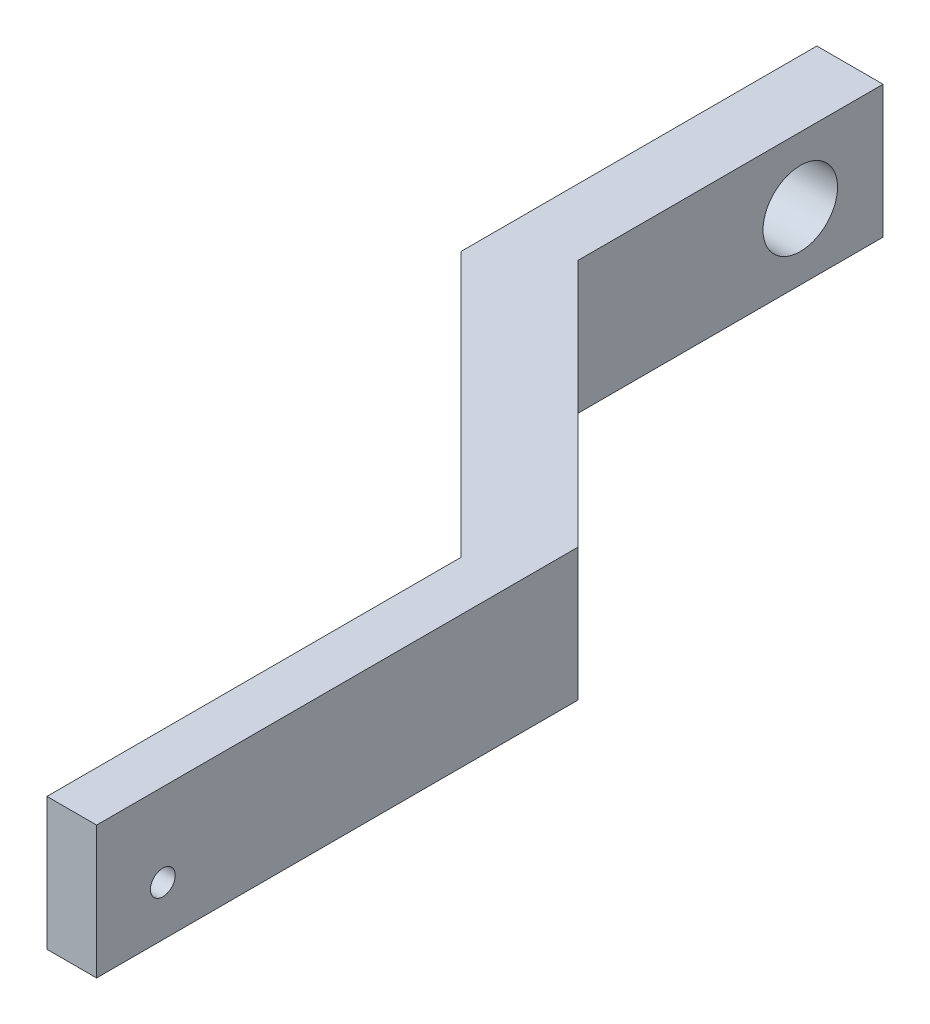
from build123d import *

# Parameters (mm, degrees)
BOSS_EXTRUDE1_DEPTH     = 8
SKETCH2_R               = 2.25
SKETCH2_R_2             = 0.75
CUT_EXTRUDE1_DEPTH      = 16
CUT_EXTRUDE1_DEPTH_BACK = 5


with BuildPart() as part:
    # Sketch1 → Boss-Extrude1 (new body)
    with BuildSketch(Plane(origin=(0, 0, 0), x_dir=(1, 0, 0), z_dir=(0, 1, 0))):
        Polygon((0, 0), (-3, 0), (-3, 25), (-19, 41), (-19, 62.5), (-15, 62.5), (-15, 44.071067812), (0, 29.071067812), align=None)
    extrude(amount=BOSS_EXTRUDE1_DEPTH)

    # Sketch2 → Cut-Extrude1 (cut, two sides)
    with BuildSketch(Plane(origin=(-15, 0, 0), x_dir=(0, 0, -1), z_dir=(1, 0, 0))) as cut_extrude1_sk:
        with Locations((57.5, 4)):
            Circle(SKETCH2_R)
        with Locations((4, 3)):
            Circle(SKETCH2_R_2)
    extrude(amount=CUT_EXTRUDE1_DEPTH, mode=Mode.SUBTRACT)
    extrude(cut_extrude1_sk.sketch, amount=-CUT_EXTRUDE1_DEPTH_BACK, mode=Mode.SUBTRACT)


solid = part.part
